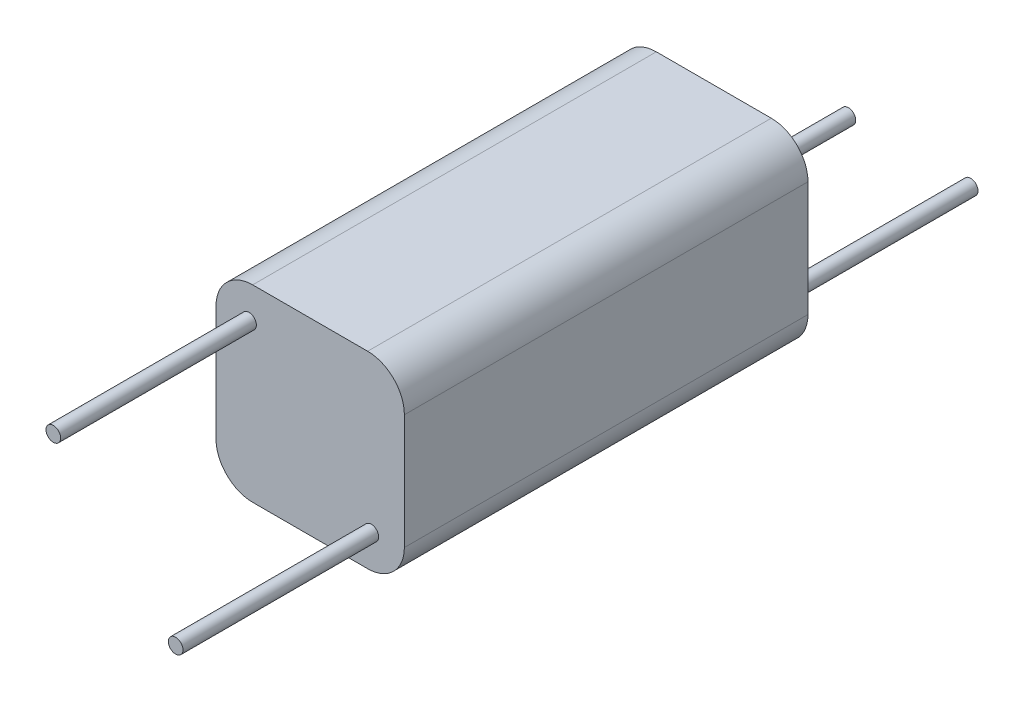
from build123d import *

# Parameters (mm, degrees)
EXTRUDE_1_DEPTH = 16.5
SKETCH_2_R      = 0.3
EXTRUDE_2_DEPTH = 8
SKETCH_3_R      = 0.3
EXTRUDE_3_DEPTH = 8


with BuildPart() as part:
    # Эскиз1 → Бобышка-Вытянуть1 (new body)
    with BuildSketch(Plane.XY):
        with BuildLine():
            Line((-2.35, -3.85), (2.35, -3.85))
            ThreePointArc((2.35, -3.85), (3.410660172, -3.410660172), (3.85, -2.35))
            Line((3.85, -2.35), (3.85, 2.35))
            ThreePointArc((3.85, 2.35), (3.410660172, 3.410660172), (2.35, 3.85))
            Line((2.35, 3.85), (-2.35, 3.85))
            ThreePointArc((-2.35, 3.85), (-3.410660172, 3.410660172), (-3.85, 2.35))
            Line((-3.85, 2.35), (-3.85, -2.35))
            ThreePointArc((-3.85, -2.35), (-3.410660172, -3.410660172), (-2.35, -3.85))
        make_face()
    extrude(amount=EXTRUDE_1_DEPTH)

    # Эскиз2 → Бобышка-Вытянуть2 (add)
    with BuildSketch(Plane(origin=(0, 0, 0), x_dir=(-1, 0, 0), z_dir=(0, 0, -1))):
        with Locations((-2.5, -2.5)):
            Circle(SKETCH_2_R)
        with Locations((2.5, -2.5)):
            Circle(SKETCH_2_R)
    extrude(amount=EXTRUDE_2_DEPTH)

    # Эскиз3 → Бобышка-Вытянуть3 (add)
    with BuildSketch(Plane.XY.offset(16.5)):
        with Locations((2.5, -2.5)):
            Circle(SKETCH_3_R)
        with Locations((-2.5, 2.5)):
            Circle(SKETCH_3_R)
    extrude(amount=EXTRUDE_3_DEPTH)


solid = part.part
